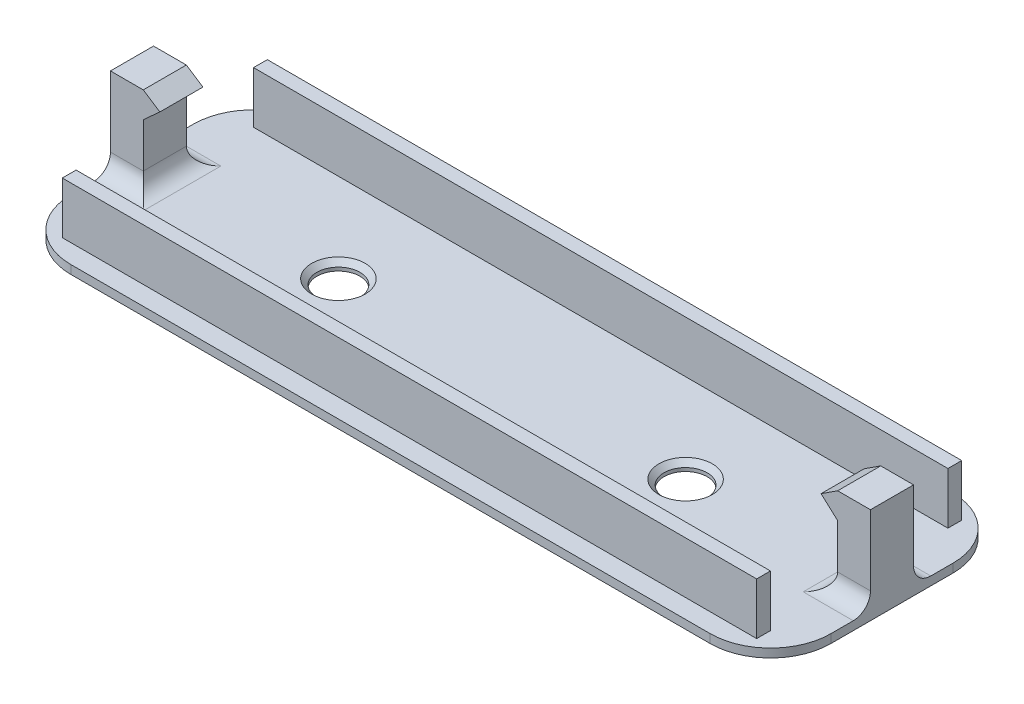
from build123d import *

# Parameters (mm, degrees)
SKETCH1_W           = 88.22
SKETCH1_H           = 28.2
SKETCH1_R           = 2.5
BOSS_EXTRUDE1_DEPTH = 1
SKETCH1_3_W         = 3.81
SKETCH1_3_H         = 5
BOSS_EXTRUDE2_DEPTH = 10.16
SKETCH1_4_W         = 80.6
SKETCH1_4_H         = 1.6
BOSS_EXTRUDE3_DEPTH = 6
BOSS_EXTRUDE4_DEPTH = 5
FILLET1_R           = 7
FILLET2_R           = 2
CHAMFER1_SIZE       = 0.6


with BuildPart() as part:
    # Sketch1 → Boss-Extrude1 (new body)
    with BuildSketch(Plane(origin=(0, 0, 0), x_dir=(1, 0, 0), z_dir=(0, 1, 0))):
        with Locations((40.3, 10.3)):
            Rectangle(SKETCH1_W, SKETCH1_H)
        with Locations((20.15, 10.3)):
            Circle(SKETCH1_R, mode=Mode.SUBTRACT)
        with Locations((60.45, 10.3)):
            Circle(SKETCH1_R, mode=Mode.SUBTRACT)
    extrude(amount=-BOSS_EXTRUDE1_DEPTH)

    # Sketch1_3 → Boss-Extrude2 (add)
    with BuildSketch(Plane(origin=(0, 0, 0), x_dir=(1, 0, 0), z_dir=(0, 1, 0))):
        with Locations((-1.905, 10.3)):
            Rectangle(SKETCH1_3_W, SKETCH1_3_H)
        with Locations((82.505, 10.3)):
            Rectangle(SKETCH1_3_W, SKETCH1_3_H)
    extrude(amount=BOSS_EXTRUDE2_DEPTH)

    # Sketch1_4 → Boss-Extrude3 (add)
    with BuildSketch(Plane(origin=(0, 0, 0), x_dir=(1, 0, 0), z_dir=(0, 1, 0))):
        with Locations((40.3, -0.8)):
            Rectangle(SKETCH1_4_W, SKETCH1_4_H)
        with Locations((40.3, 21.4)):
            Rectangle(SKETCH1_4_W, SKETCH1_4_H)
    extrude(amount=BOSS_EXTRUDE3_DEPTH)

    # Sketch2 → Boss-Extrude4 (add)
    with BuildSketch(Plane.XY.offset(-7.8)):
        Polygon((0, 10.16), (1.927427041, 8.905), (0, 7.16), align=None)
    boss_extrude4 = extrude(amount=-BOSS_EXTRUDE4_DEPTH)

    # Mirror1: Boss-Extrude4 across plane
    add(boss_extrude4.mirror(Plane.ZY.offset(-40.3)))

    # Fillet1
    fillet1_edges = [part.edges().sort_by_distance(p)[0] for p in [
        (84.41, -0.5, 3.8),
        (-3.81, -0.5, 3.8),
        (-3.81, -0.5, -24.4),
        (84.41, -0.5, -24.4),
    ]]
    fillet(fillet1_edges, radius=FILLET1_R)

    # Fillet2
    fillet2_edges = [part.edges().sort_by_distance(p)[0] for p in [
        (0, 0, -10.3),
        (-1.905, 0, -12.8),
        (-1.905, 0, -7.8),
        (82.505, 0, -7.8),
        (80.6, 0, -10.3),
        (82.505, 0, -12.8),
    ]]
    fillet(fillet2_edges, radius=FILLET2_R)

    # Chamfer1
    chamfer1_edges = [part.edges().sort_by_distance(p)[0] for p in [
        (17.65, 0, -10.3),
        (57.95, 0, -10.3),
    ]]
    chamfer(chamfer1_edges, length=CHAMFER1_SIZE)


solid = part.part
